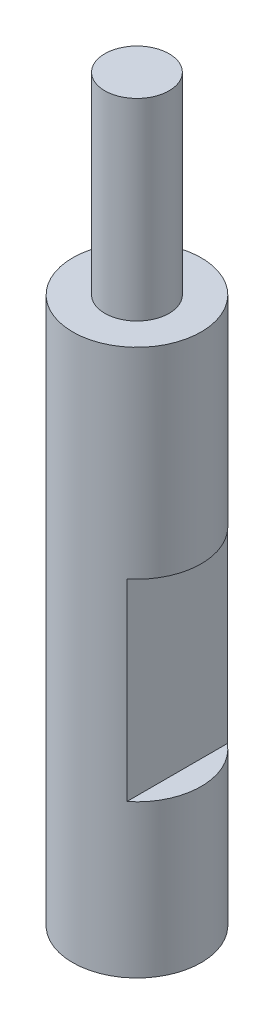
from build123d import *

# Parameters (mm, degrees)
SKETCH1_R                   = 4
BOSS_EXTRUDE1_DEPTH         = 34
SKETCH2_R                   = 2
BOSS_EXTRUDE2_DEPTH         = 12
SKETCH3_W                   = 1.5
SKETCH3_H                   = 12
CUT_EXTRUDE1_DEPTH          = 5
CUT_EXTRUDE1_DEPTH_BACK     = 5
M3_TAPPED_HOLE1_D           = 2.5
M3_TAPPED_HOLE1_DEPTH       = 14
M3_TAPPED_HOLE1_CSINK_D     = 3.05
M3_TAPPED_HOLE1_CSINK_ANGLE = 90
M3_TAPPED_HOLE1_TIP         = 0.751075774
SKETCH7_R                   = 2
CUT_EXTRUDE2_DEPTH          = 12


with BuildPart() as part:
    # Sketch1 → Boss-Extrude1 (new body)
    with BuildSketch(Plane(origin=(0, 0, 0), x_dir=(1, 0, 0), z_dir=(0, 1, 0))):
        Circle(SKETCH1_R)
    extrude(amount=BOSS_EXTRUDE1_DEPTH)

    # Sketch2 → Boss-Extrude2 (add)
    with BuildSketch(Plane(origin=(0, 34, 0), x_dir=(1, 0, 0), z_dir=(0, 1, 0))):
        Circle(SKETCH2_R)
    extrude(amount=BOSS_EXTRUDE2_DEPTH)

    # Sketch3 → Cut-Extrude1 (cut, two sides)
    with BuildSketch(Plane.XY) as cut_extrude1_sk:
        with Locations((3.25, 15.5)):
            Rectangle(SKETCH3_W, SKETCH3_H)
    extrude(amount=CUT_EXTRUDE1_DEPTH, mode=Mode.SUBTRACT)
    extrude(cut_extrude1_sk.sketch, amount=-CUT_EXTRUDE1_DEPTH_BACK, mode=Mode.SUBTRACT)

    # M3 Tapped Hole1
    with Locations(Plane(origin=(0, 0, 0), x_dir=(-1, 0, 0), z_dir=(0, -1, 0))):
        with Locations((0, 0)):
            CounterSinkHole(M3_TAPPED_HOLE1_D / 2, M3_TAPPED_HOLE1_CSINK_D / 2, depth=M3_TAPPED_HOLE1_DEPTH, counter_sink_angle=M3_TAPPED_HOLE1_CSINK_ANGLE)
            with Locations((0, 0, -(M3_TAPPED_HOLE1_DEPTH + M3_TAPPED_HOLE1_TIP / 2))):  # 118° drill point
                Cone(0, M3_TAPPED_HOLE1_D / 2, M3_TAPPED_HOLE1_TIP, mode=Mode.SUBTRACT)

    # Sketch7 → Cut-Extrude2 (cut)
    with BuildSketch(Plane(origin=(0, 0, 0), x_dir=(0, 0, -1), z_dir=(1, 0, 0))):
        with Locations((0, 11.5)):
            Circle(SKETCH7_R)
    extrude(amount=-CUT_EXTRUDE2_DEPTH, mode=Mode.SUBTRACT)


solid = part.part
